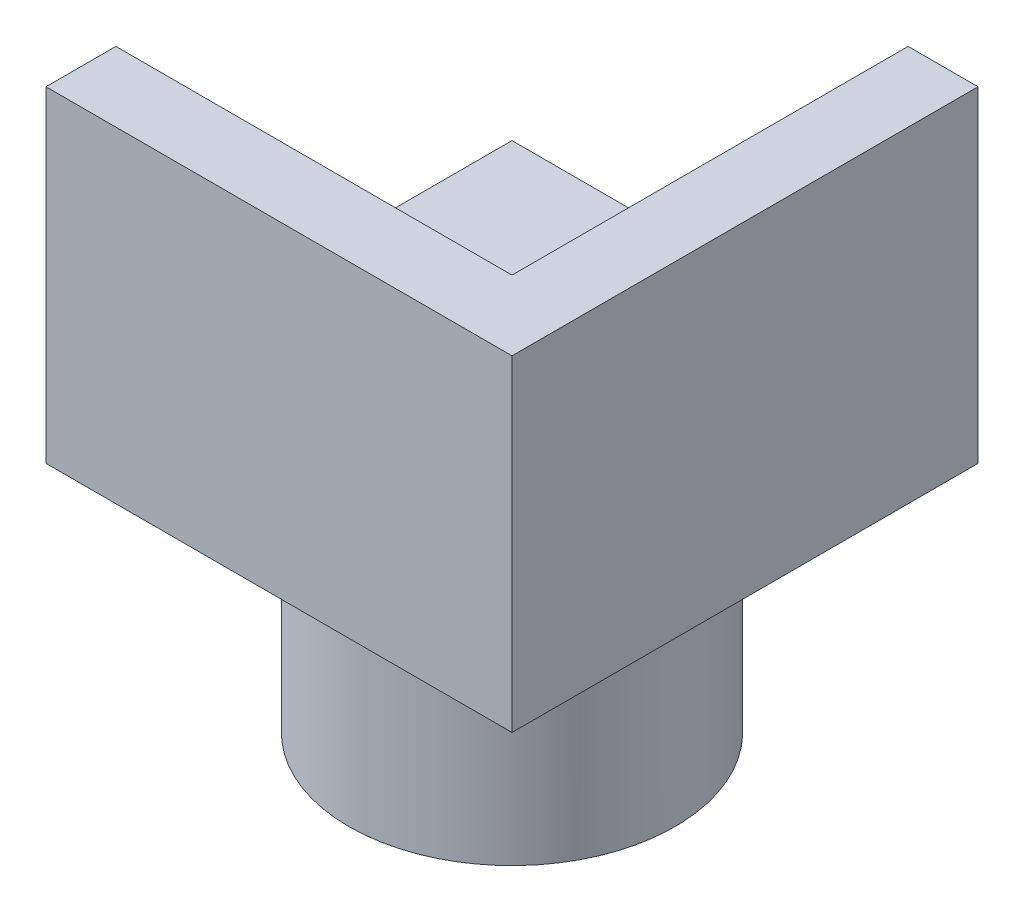
from build123d import *

# Parameters (mm, degrees)
SKETCH1_W           = 10
SKETCH1_H           = 10
BOSS_EXTRUDE1_DEPTH = 1
CUT_EXTRUDE1_DEPTH  = 1.5
SKETCH3_R           = 3.5
BOSS_EXTRUDE2_DEPTH = 5
SKETCH4_R           = 2
CUT_EXTRUDE2_DEPTH  = 6
BOSS_EXTRUDE3_DEPTH = 6


with BuildPart() as part:
    # Sketch1 → Boss-Extrude1 (new body)
    with BuildSketch(Plane(origin=(0, 0, 0), x_dir=(1, 0, 0), z_dir=(0, 1, 0))):
        Rectangle(SKETCH1_W, SKETCH1_H)
    extrude(amount=BOSS_EXTRUDE1_DEPTH)

    # Sketch2 → Cut-Extrude1 (cut)
    with BuildSketch(Plane(origin=(0, 1, 0), x_dir=(1, 0, 0), z_dir=(0, 1, 0))):
        with BuildLine():
            Line((2.5, 0.5), (2.5, -0.5))
            ThreePointArc((2.5, -0.5), (0, -3), (-2.5, -0.5))
            Line((-2.5, -0.5), (-2.5, 0.5))
            ThreePointArc((-2.5, 0.5), (0, 3), (2.5, 0.5))
        make_face()
    extrude(amount=-CUT_EXTRUDE1_DEPTH, mode=Mode.SUBTRACT)

    # Sketch3 → Boss-Extrude2 (add)
    with BuildSketch(Plane.XZ):
        Circle(SKETCH3_R)
    extrude(amount=BOSS_EXTRUDE2_DEPTH)

    # Sketch4 → Cut-Extrude2 (cut, through all)
    with BuildSketch(Plane(origin=(0, 0, 0), x_dir=(1, 0, 0), z_dir=(0, 1, 0))):
        Circle(SKETCH4_R)
    extrude(amount=-CUT_EXTRUDE2_DEPTH, mode=Mode.SUBTRACT)

    # Sketch6 → Boss-Extrude3 (add)
    with BuildSketch(Plane(origin=(0, 1, 0), x_dir=(1, 0, 0), z_dir=(0, 1, 0))):
        Polygon((3.5, 3.5), (3.5, 5), (5, 5), (5, -5), (-5, -5), (-5, -3.5), (3.5, -3.5), align=None)
    extrude(amount=BOSS_EXTRUDE3_DEPTH)


solid = part.part
